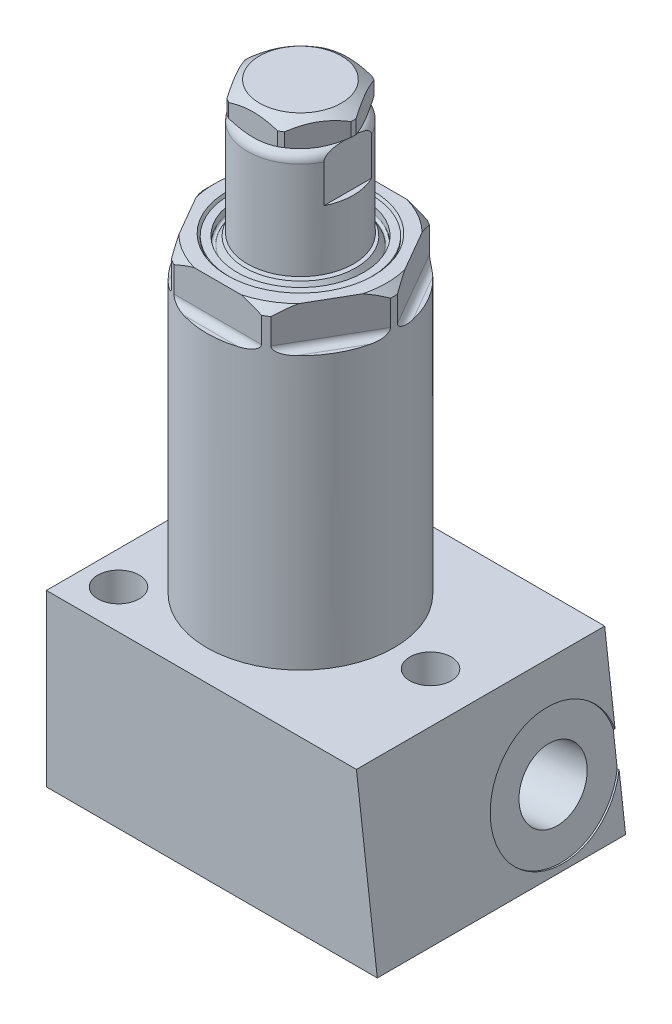
from build123d import *

# Parameters (mm, degrees)
SKETCH2_OUTSIDE_W   = 40.384
SKETCH2_OUTSIDE_H   = 40.384
CUT_EXTRUDE1_DEPTH  = 5.334
FILLET1_R           = 0.9144
SKETCH4_W           = 0.762
SKETCH4_H           = 6.35
CUT_EXTRUDE2_DEPTH  = 11.1125
SKETCH5_W           = 3.4417
SKETCH5_H           = 5.08
SKETCH8_OUTSIDE_W   = 43.518
SKETCH8_OUTSIDE_H   = 43.518
CUT_EXTRUDE3_DEPTH  = 3.556
BOSS_EXTRUDE1_DEPTH = 16.6751
SKETCH10_R          = 2.7813
CUT_EXTRUDE4_DEPTH  = 33.3502
SKETCH11_R          = 8.636
CUT_EXTRUDE5_DEPTH  = 0.254
SKETCH12_R          = 4.5466
CUT_EXTRUDE6_DEPTH  = 12.192
SKETCH13_R          = 6.35
CUT_EXTRUDE7_DEPTH  = 2.54
SKETCH14_R          = 4.5085
CUT_EXTRUDE8_DEPTH  = 2.286
SKETCH15_R          = 3.4544
CUT_EXTRUDE9_DEPTH  = 12.2936


with BuildPart() as part:
    # Sketch1 → Revolve1 (revolve)
    with BuildSketch(Plane.XY):
        with BuildLine():
            Line((7.9375, 0), (8.7376, 0))
            Line((8.7376, 0), (9.1186, 0.381))
            Line((9.1186, 0.381), (10.9093, 0.381))
            Line((10.9093, 0.381), (11.6713, 1.143))
            Line((11.6713, 1.143), (11.6713, 6.1214))
            Line((11.6713, 6.1214), (12.573, 7.0231))
            Line((12.573, 7.0231), (12.573, 54.356))
            Line((12.573, 54.356), (11.557, 55.372))
            Line((11.557, 55.372), (9.818293937, 55.372))
            Line((9.818293937, 55.372), (9.525, 54.864))
            Line((9.525, 54.864), (9.525, 55.0926))
            Line((9.525, 55.0926), (8.509, 55.0926))
            Line((8.509, 55.0926), (8.509, 54.2036))
            ThreePointArc((8.509, 54.2036), (8.320740037, 53.95825484), (8.035029547, 54.0766))
            Line((8.035029547, 54.0766), (7.448441674, 55.0926))
            Line((7.448441674, 55.0926), (0, 55.0926))
            Line((0, 55.0926), (0, 5.1308))
            Line((0, 5.1308), (2.3876, 5.1308))
            Line((2.3876, 5.1308), (2.3876, 1.3208))
            Line((2.3876, 1.3208), (7.0485, 1.3208))
            ThreePointArc((7.0485, 1.3208), (6.419882072, -0.196817928), (7.9375, 0.4318))
            Line((7.9375, 0.4318), (7.9375, 0))
        make_face()
    revolve(axis=Axis((0, 0, 0), (0, 1, 0)))

    # Sketch2 outside → Cut-Extrude1 (cut)
    with BuildSketch(Plane(origin=(0, 55.372, 0), x_dir=(1, 0, 0), z_dir=(0, 1, 0))):
        Rectangle(SKETCH2_OUTSIDE_W, SKETCH2_OUTSIDE_H)
        Polygon((12.831609733, 0), (6.415804866, 11.1125), (-6.415804866, 11.1125), (-12.831609733, 0), (-6.415804866, -11.1125), (6.415804866, -11.1125), align=None, mode=Mode.SUBTRACT)
    extrude(amount=-CUT_EXTRUDE1_DEPTH, mode=Mode.SUBTRACT)

    # Fillet1
    fillet1_edges = [part.edges().sort_by_distance(p)[0] for p in [
        (-9.6237073, 50.038, -5.55625),
        (0, 50.038, -11.1125),
        (9.6237073, 50.038, -5.55625),
        (9.6237073, 50.038, 5.55625),
        (0, 50.038, 11.1125),
        (-9.6237073, 50.038, 5.55625),
    ]]
    fillet(fillet1_edges, radius=FILLET1_R)

    # Sketch9 → Boss-Extrude1 (add, symmetric)
    with BuildSketch(Plane.XY):
        Polygon((-17.4498, 13.462), (-17.4498, -9.398), (27.0002, -9.398), (24.193344938, 13.462), align=None)
    extrude(amount=BOSS_EXTRUDE1_DEPTH, both=True)

    # Sketch10 → Cut-Extrude4 (cut)
    with BuildSketch(Plane(origin=(0, 13.462, 0), x_dir=(1, 0, 0), z_dir=(0, 1, 0))):
        with Locations(Location((17.4752, 0, 0), (0, 0, 180))):  # turned: the seam where the file's is
            Circle(SKETCH10_R)
        with Locations(Location((-13.0048, 11.43, 0), (0, 0, 180))):  # turned: the seam where the file's is
            Circle(SKETCH10_R)
        with Locations(Location((-13.0048, -11.43, 0), (0, 0, 180))):  # turned: the seam where the file's is
            Circle(SKETCH10_R)
    extrude(amount=-CUT_EXTRUDE4_DEPTH, mode=Mode.SUBTRACT)

    # Sketch11 → Cut-Extrude5 (cut)
    with BuildSketch(Plane(origin=(25.462398347, 3.126389401, 0), x_dir=(0, 0, -1), z_dir=(0.992546152, 0.121869343, 0))):
        with Locations((8.3312, -3.220445379)):
            Circle(SKETCH11_R)
    extrude(amount=-CUT_EXTRUDE5_DEPTH, mode=Mode.SUBTRACT)

    # Sketch12 → Cut-Extrude6 (cut)
    with BuildSketch(Plane(origin=(25.210291624, 3.095434587, 0), x_dir=(0, 0, -1), z_dir=(0.992546152, 0.121869343, 0))):
        with Locations(Location((8.3312, -3.220445379, 0), (0, 0, 90))):  # turned: the seam where the file's is
            Circle(SKETCH12_R)
    extrude(amount=-CUT_EXTRUDE6_DEPTH, mode=Mode.SUBTRACT)

    # Sketch13 → Cut-Extrude7 (cut)
    with BuildSketch(Plane.XZ.offset(9.398)):
        with Locations(Location((17.4752, 9.7282, 0), (0, 0, 270))):  # turned: the seam where the file's is
            Circle(SKETCH13_R)
    extrude(amount=-CUT_EXTRUDE7_DEPTH, mode=Mode.SUBTRACT)

    # Sketch14 → Cut-Extrude8 (cut)
    with BuildSketch(Plane.XZ.offset(6.858)):
        with Locations(Location((17.4752, 9.7282, 0), (0, 0, 270))):  # turned: the seam where the file's is
            Circle(SKETCH14_R)
    extrude(amount=-CUT_EXTRUDE8_DEPTH, mode=Mode.SUBTRACT)

    # Sketch15 → Cut-Extrude9 (cut)
    with BuildSketch(Plane.XZ.offset(4.572)):
        with Locations(Location((17.4752, 9.7282, 0), (0, 0, 270))):  # turned: the seam where the file's is
            Circle(SKETCH15_R)
    extrude(amount=-CUT_EXTRUDE9_DEPTH, mode=Mode.SUBTRACT)


with BuildPart() as body_2:
    # Sketch3 → Revolve2 (revolve)
    with BuildSketch(Plane.XY):
        with BuildLine():
            Line((0, 55.372), (0, 69.723))
            Line((0, 69.723), (5.842, 69.723))
            ThreePointArc((5.842, 69.723), (6.740025612, 69.351025612), (7.112, 68.453))
            Line((7.112, 68.453), (7.112, 55.372))
            Line((7.112, 55.372), (0, 55.372))
        make_face()
    revolve(axis=Axis((0, 43.688, 0), (0, 1, 0)))

    # Sketch4 → Cut-Extrude2 (cut, symmetric)
    with BuildSketch(Plane.XY):
        with Locations((-6.731, 66.548)):
            Rectangle(SKETCH4_W, SKETCH4_H)
        with Locations((6.731, 66.548)):
            Rectangle(SKETCH4_W, SKETCH4_H)
    extrude(amount=CUT_EXTRUDE2_DEPTH, both=True, mode=Mode.SUBTRACT)

    # Sketch5 → 5_16-18 Tapped Hole1 (revolve, cut)
    with BuildSketch(Plane(origin=(0, 69.723, 0), x_dir=(0, 0, 1), z_dir=(1, 0, 0))):
        with Locations((1.72085, 2.54)):
            Rectangle(SKETCH5_W, SKETCH5_H)
    revolve(axis=Axis((0, 76.073, 0), (0, -1, 0)), mode=Mode.SUBTRACT)

    # Sketch7 → Revolve3 (revolve)
    with BuildSketch(Plane.XY):
        Polygon((0, 73.279), (5.4991, 73.279), (7.1501, 72.122957354), (7.1501, 70.283236051), (6.35, 69.723), (0, 69.723), align=None)
    revolve(axis=Axis((0, 0, 0), (0, -1, 0)))

    # Sketch8 outside → Cut-Extrude3 (cut)
    with BuildSketch(Plane(origin=(0, 73.279, 0), x_dir=(1, 0, 0), z_dir=(0, 1, 0))):
        Rectangle(SKETCH8_OUTSIDE_W, SKETCH8_OUTSIDE_H)
        Polygon((7.332348419, 0), (3.666174209, 6.35), (-3.666174209, 6.35), (-7.332348419, 0), (-3.666174209, -6.35), (3.666174209, -6.35), align=None, mode=Mode.SUBTRACT)
    extrude(amount=-CUT_EXTRUDE3_DEPTH, mode=Mode.SUBTRACT)


solid = Compound([part.part, body_2.part])
